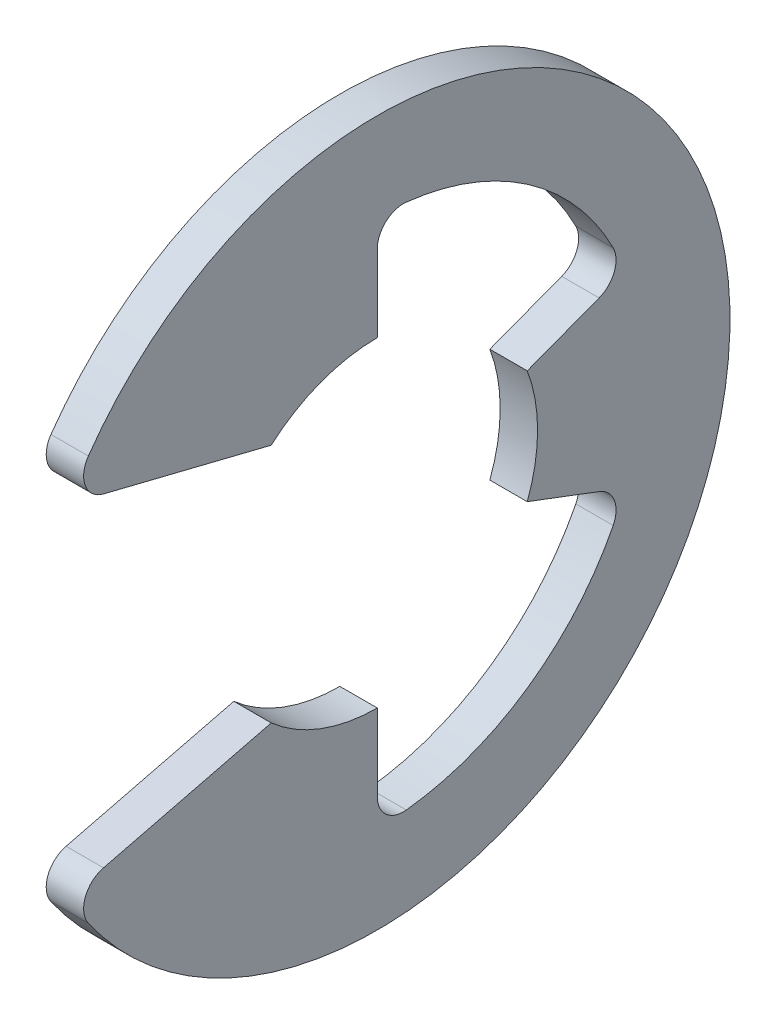
from build123d import *

# Parameters (mm, degrees)
EXTRUDE1_DEPTH = 0.4445
FILLET1_R      = 0.6223


with BuildPart() as part:
    # Sketch1 → Extrude1 (new body, symmetric)
    with BuildSketch(Plane(origin=(0, 0, 0), x_dir=(0, 0, -1), z_dir=(1, 0, 0))):
        with BuildLine():
            Line((-7.336785518, -4.053332241), (-2.520078124, -2.8575))
            ThreePointArc((-2.520078124, -2.8575), (-1.347038418, -3.563928661), (0, -3.81))
            Line((0, -3.81), (0, -6.292645161))
            ThreePointArc((0, -6.292645161), (3.57754064, -5.176735081), (5.886230563, -2.224786033))
            Line((5.886230563, -2.224786033), (3.563928661, -1.347038418))
            ThreePointArc((3.563928661, -1.347038418), (3.81, 0), (3.563928661, 1.347038418))
            Line((3.563928661, 1.347038418), (5.886230563, 2.224786033))
            ThreePointArc((5.886230563, 2.224786033), (3.57754064, 5.176735081), (0, 6.292645161))
            Line((0, 6.292645161), (0, 3.81))
            ThreePointArc((0, 3.81), (-1.347038418, 3.563928661), (-2.520078124, 2.8575))
            Line((-2.520078124, 2.8575), (-7.336785518, 4.053332241))
            ThreePointArc((-7.336785518, 4.053332241), (8.382, 0), (-7.336785518, -4.053332241))
        make_face()
    extrude(amount=EXTRUDE1_DEPTH, both=True)

    # Fillet1
    fillet1_edges = [part.edges().sort_by_distance(p)[0] for p in [
        (0, -4.053332241, 7.336785518),
        (0, -6.292645161, 0),
        (0, -2.224786033, -5.886230563),
        (0, 2.224786033, -5.886230563),
        (0, 6.292645161, 0),
        (0, 4.053332241, 7.336785518),
    ]]
    fillet(fillet1_edges, radius=FILLET1_R)


solid = part.part
